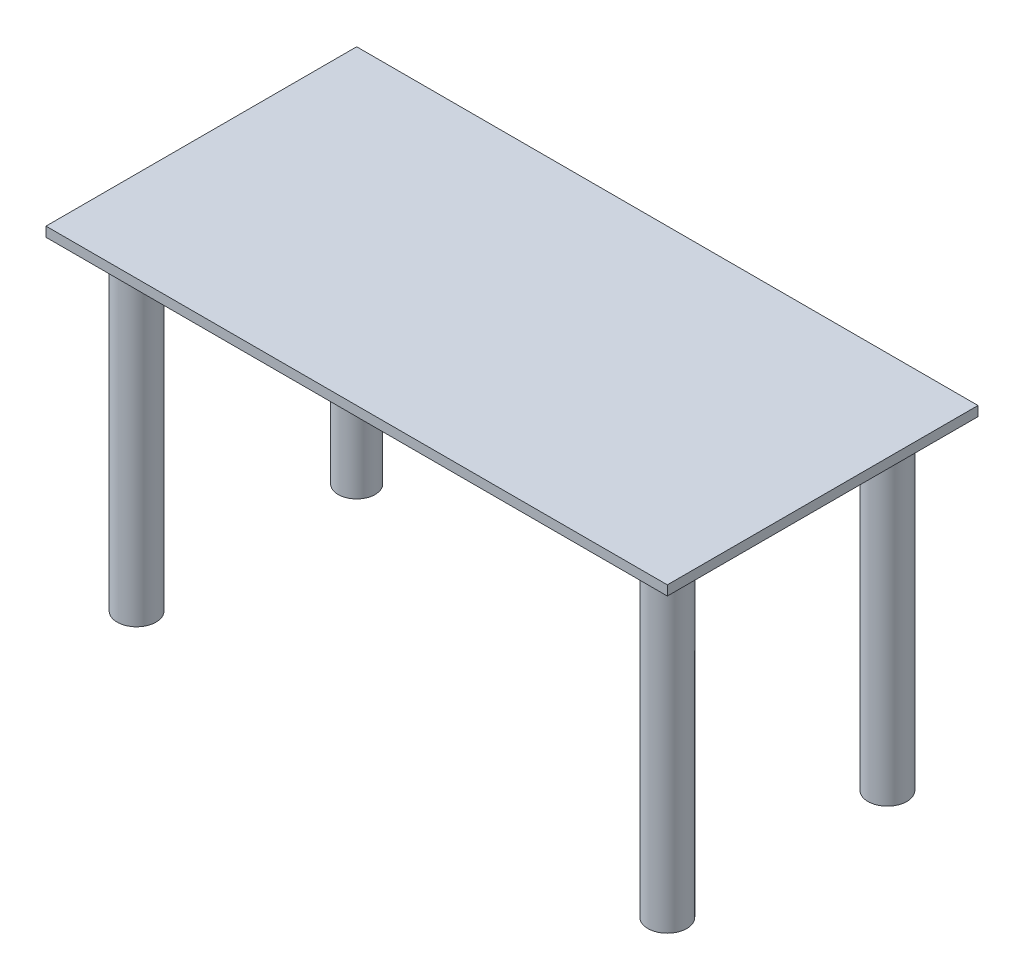
from build123d import *

# Parameters (mm, degrees)
SKETCH1_W           = 1219.2
SKETCH1_H           = 609.6
BOSS_EXTRUDE1_DEPTH = 19.05
SKETCH2_R           = 63.5
BOSS_EXTRUDE2_DEPTH = 25.4
SKETCH3_R           = 38.1
SKETCH3_R_2         = 36.165456998
BOSS_EXTRUDE3_DEPTH = 609.6
SKETCH4_R           = 31.75
CUT_EXTRUDE1_DEPTH  = 584.2


with BuildPart() as part:
    # Sketch1 → Boss-Extrude1 (new body)
    with BuildSketch(Plane(origin=(0, 0, 0), x_dir=(1, 0, 0), z_dir=(0, 1, 0))):
        Rectangle(SKETCH1_W, SKETCH1_H)
    extrude(amount=BOSS_EXTRUDE1_DEPTH)

    # Sketch2 → Boss-Extrude2 (add)
    with BuildSketch(Plane.XZ):
        with Locations((-520.7, 215.9)):
            Circle(SKETCH2_R)
        with Locations((-520.7, -215.9)):
            Circle(SKETCH2_R)
        with Locations((520.7, 215.9)):
            Circle(SKETCH2_R)
        with Locations((520.7, -215.9)):
            Circle(SKETCH2_R)
    extrude(amount=BOSS_EXTRUDE2_DEPTH)

    # Sketch3 → Boss-Extrude3 (add)
    with BuildSketch(Plane.XZ.offset(25.4)):
        with Locations((-520.7, 215.9)):
            Circle(SKETCH3_R)
        with Locations((-520.7, -215.9)):
            Circle(SKETCH3_R_2)
        with Locations((520.7, 215.9)):
            Circle(SKETCH3_R)
        with Locations((520.7, -215.9)):
            Circle(SKETCH3_R)
    extrude(amount=BOSS_EXTRUDE3_DEPTH)

    # Sketch4 → Cut-Extrude1 (cut)
    with BuildSketch(Plane.XZ.offset(635)):
        with Locations((-520.7, 215.9)):
            Circle(SKETCH4_R)
        with Locations((520.7, 215.9)):
            Circle(SKETCH4_R)
        with Locations((520.7, -215.9)):
            Circle(SKETCH4_R)
        with Locations((-520.7, -215.9)):
            Circle(SKETCH4_R)
    extrude(amount=-CUT_EXTRUDE1_DEPTH, mode=Mode.SUBTRACT)


solid = part.part
